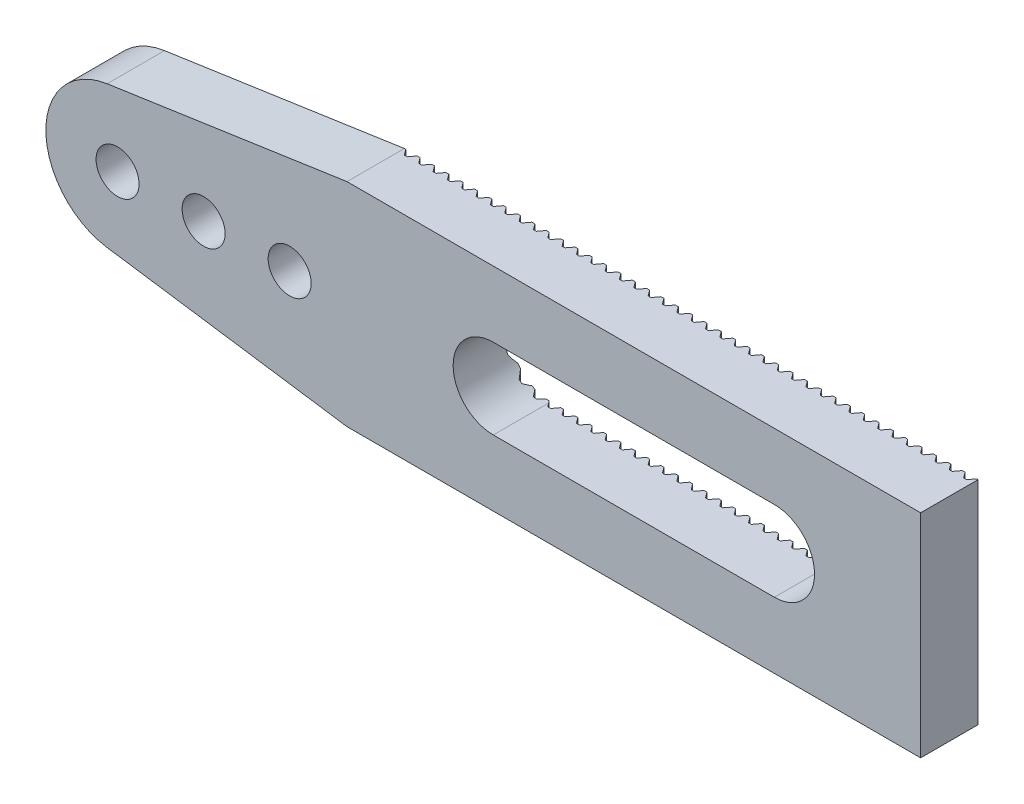
from build123d import *

# Parameters (mm, degrees)
ESQUISSE1_R                = 0.75
BOSS_EXTRU_1_DEPTH         = 2
ENL_V_MAT_EXTRU_1_DEPTH    = 8.4
R_P_TITION_LIN_AIRE1_COUNT = 40
R_P_TITION_LIN_AIRE1_PITCH = 0.5


with BuildPart() as part:
    # Esquisse1 → Boss.-Extru.1 (new body)
    with BuildSketch(Plane.XY):
        with BuildLine():
            Line((-10, 3.7), (-18.362762549, 2.473540647))
            ThreePointArc((-18.362762549, 2.473540647), (-20.5, 0), (-18.362762549, -2.473540647))
            Line((-18.362762549, -2.473540647), (-10, -3.7))
            Line((-10, -3.7), (10, -3.7))
            Line((10, -3.7), (10, 3.7))
            Line((10, 3.7), (-10, 3.7))
        make_face()
        with Locations((-18, 0)):
            Circle(ESQUISSE1_R, mode=Mode.SUBTRACT)
        with Locations((-15, 0)):
            Circle(ESQUISSE1_R, mode=Mode.SUBTRACT)
        with Locations((-12, 0)):
            Circle(ESQUISSE1_R, mode=Mode.SUBTRACT)
        with BuildLine():
            Line((-4.9, 1.4), (4.9, 1.4))
            ThreePointArc((4.9, 1.4), (6.3, 0), (4.9, -1.4))
            Line((4.9, -1.4), (-4.9, -1.4))
            ThreePointArc((-4.9, -1.4), (-6.3, 0), (-4.9, 1.4))
        make_face(mode=Mode.SUBTRACT)
    extrude(amount=BOSS_EXTRU_1_DEPTH)

    # Esquisse2 → Enlèv. mat.-Extru.1 (cut, through all)
    with BuildSketch(Plane(origin=(0, 3.7, 0), x_dir=(1, 0, 0), z_dir=(0, 1, 0))):
        Polygon((9.95, 0), (9.55, 0), (9.7, -0.2), (9.8, -0.2), align=None)
    enl_v_mat_extru_1 = extrude(amount=-ENL_V_MAT_EXTRU_1_DEPTH, mode=Mode.SUBTRACT)

    # Répétition linéaire1: Enlèv. mat.-Extru.1 ×40
    with Locations(*[(-i * R_P_TITION_LIN_AIRE1_PITCH, 0, 0) for i in range(1, R_P_TITION_LIN_AIRE1_COUNT)]):
        add(enl_v_mat_extru_1, mode=Mode.SUBTRACT)


solid = part.part
